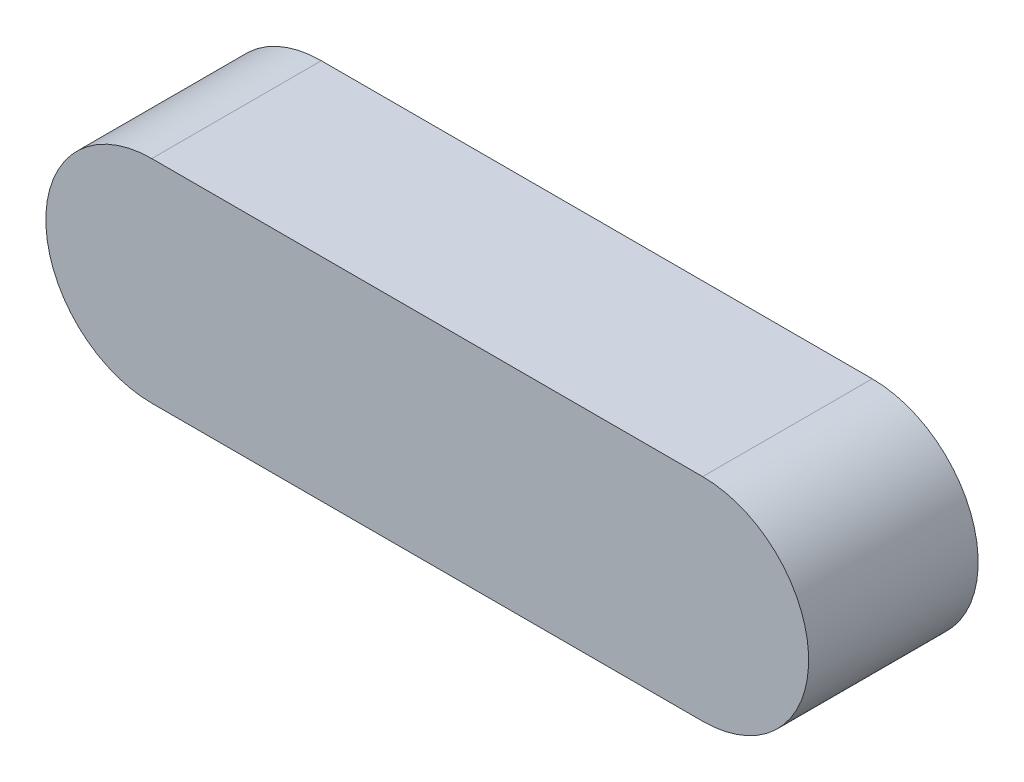
from build123d import *

# Parameters (mm, degrees)
BOSS_EXTRUDE1_DEPTH = 8


with BuildPart() as part:
    # Sketch1 → Boss-Extrude1 (new body)
    with BuildSketch(Plane.XY):
        with BuildLine():
            Line((-5.415019763, 5), (20.584980237, 5))
            ThreePointArc((20.584980237, 5), (25.584980237, 0), (20.584980237, -5))
            Line((20.584980237, -5), (-5.415019763, -5))
            ThreePointArc((-5.415019763, -5), (-10.415019763, 0), (-5.415019763, 5))
        make_face()
    extrude(amount=BOSS_EXTRUDE1_DEPTH)


solid = part.part
